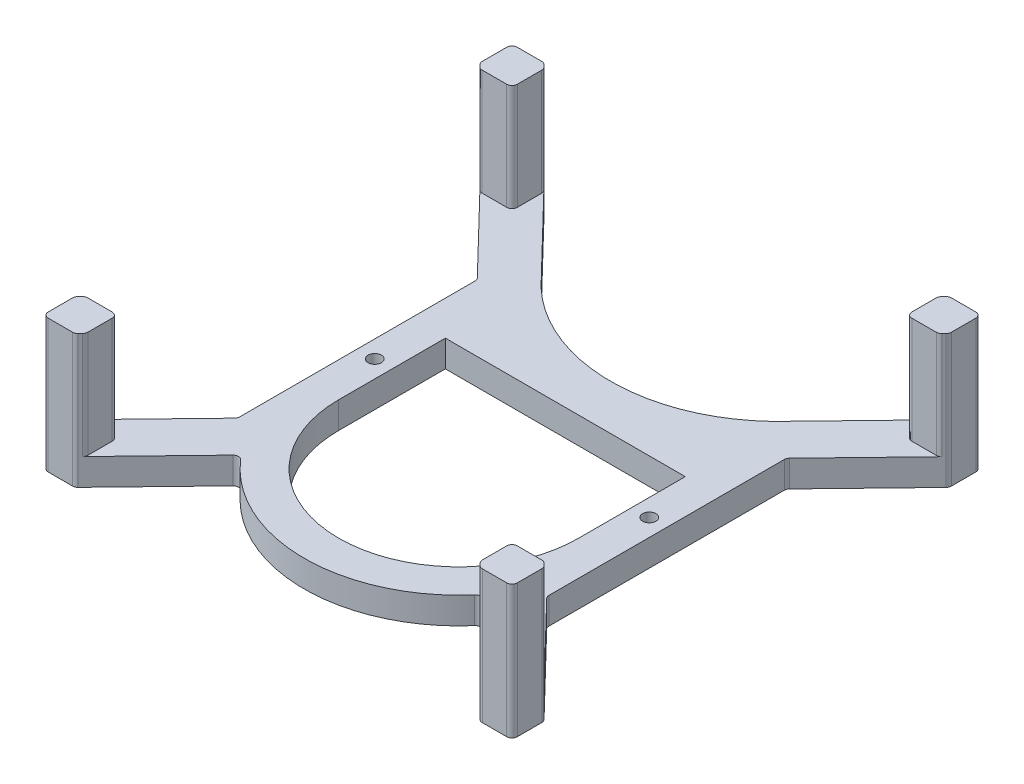
from build123d import *

# Parameters (mm, degrees)
BOSS_EXTRUDE1_DEPTH             = 5
BOSS_EXTRUDE2_DEPTH             = 20
TAP_DRILL_FOR_M3X0_5_TAP1_D     = 2.5
TAP_DRILL_FOR_M3X0_5_TAP1_DEPTH = 6
TAP_DRILL_FOR_M3X0_5_TAP1_TIP   = 0.751075774


with BuildPart() as part:
    # Sketch1 → Boss-Extrude1 (new body)
    with BuildSketch(Plane(origin=(0, 0, 0), x_dir=(1, 0, 0), z_dir=(0, 1, 0))):
        with BuildLine():
            Line((21, 27.921142965), (21, 72.078857035))
            ThreePointArc((21, 72.078857035), (20.927086518, 72.453704455), (20.718978822, 72.773889015))
            Line((20.718978822, 72.773889015), (6.281021178, 87.709296434))
            ThreePointArc((6.281021178, 87.709296434), (6.072913482, 88.029480993), (6, 88.404328413))
            Line((6, 88.404328413), (6, 93))
            ThreePointArc((6, 93), (6.292893219, 93.707106781), (7, 94))
            Line((7, 94), (11.575831706, 94))
            ThreePointArc((11.575831706, 94), (11.966323717, 93.920606316), (12.294810529, 93.69503198))
            Line((12.294810529, 93.69503198), (26.579929079, 78.91772962))
            ThreePointArc((26.579929079, 78.91772962), (50, 68.488702878), (73.420070921, 78.91772962))
            Line((73.420070921, 78.91772962), (87.705189471, 93.69503198))
            ThreePointArc((87.705189471, 93.69503198), (88.033676283, 93.920606316), (88.424168294, 94))
            Line((88.424168294, 94), (93, 94))
            ThreePointArc((93, 94), (93.707106781, 93.707106781), (94, 93))
            Line((94, 93), (94, 88.404328413))
            ThreePointArc((94, 88.404328413), (93.927086518, 88.029480993), (93.718978822, 87.709296434))
            Line((93.718978822, 87.709296434), (79.281021178, 72.773889015))
            ThreePointArc((79.281021178, 72.773889015), (79.072913482, 72.453704455), (79, 72.078857035))
            Line((79, 72.078857035), (79, 27.921142965))
            ThreePointArc((79, 27.921142965), (79.072913482, 27.546295545), (79.281021178, 27.226110985))
            Line((79.281021178, 27.226110985), (93.718978822, 12.290703566))
            ThreePointArc((93.718978822, 12.290703566), (93.927086518, 11.970519007), (94, 11.595671587))
            Line((94, 11.595671587), (94, 7))
            ThreePointArc((94, 7), (93.707106781, 6.292893219), (93, 6))
            Line((93, 6), (88.424168294, 6))
            ThreePointArc((88.424168294, 6), (88.033676283, 6.079393684), (87.705189471, 6.30496802))
            Line((87.705189471, 6.30496802), (73.420070921, 21.08227038))
            ThreePointArc((73.420070921, 21.08227038), (72.67313409, 21.386847499), (71.944389028, 21.040997121))
            ThreePointArc((71.944389028, 21.040997121), (50, 11), (28.055610972, 21.040997121))
            ThreePointArc((28.055610972, 21.040997121), (27.32686591, 21.386847499), (26.579929079, 21.08227038))
            Line((26.579929079, 21.08227038), (12.294810529, 6.30496802))
            ThreePointArc((12.294810529, 6.30496802), (11.966323717, 6.079393684), (11.575831706, 6))
            Line((11.575831706, 6), (7, 6))
            ThreePointArc((7, 6), (6.292893219, 6.292893219), (6, 7))
            Line((6, 7), (6, 11.595671587))
            ThreePointArc((6, 11.595671587), (6.072913482, 11.970519007), (6.281021178, 12.290703566))
            Line((6.281021178, 12.290703566), (20.718978822, 27.226110985))
            ThreePointArc((20.718978822, 27.226110985), (20.927086518, 27.546295545), (21, 27.921142965))
        make_face()
        with BuildLine():
            Line((27.5, 40), (27.5, 60))
            Line((27.5, 60), (72.5, 60))
            Line((72.5, 60), (72.5, 40))
            ThreePointArc((72.5, 40), (50, 17.5), (27.5, 40))
        make_face(mode=Mode.SUBTRACT)
    extrude(amount=BOSS_EXTRUDE1_DEPTH)

    # Sketch2 → Boss-Extrude2 (add)
    with BuildSketch(Plane(origin=(0, 5, 0), x_dir=(1, 0, 0), z_dir=(0, 1, 0))):
        with BuildLine():
            Line((11.575831706, 94), (7, 94))
            ThreePointArc((7, 94), (6.292893219, 93.707106781), (6, 93))
            Line((6, 93), (6, 88.404328413))
            ThreePointArc((6, 88.404328413), (6.072913482, 88.029480993), (6.281021178, 87.709296434))
            Line((6.281021178, 87.709296434), (6.671882728, 87.30496802))
            ThreePointArc((6.671882728, 87.30496802), (7.00036954, 87.079393684), (7.390861551, 87))
            Line((7.390861551, 87), (12, 87))
            ThreePointArc((12, 87), (12.707106781, 87.292893219), (13, 88))
            Line((13, 88), (13, 92.561217283))
            ThreePointArc((13, 92.561217283), (12.927086518, 92.936064704), (12.718978822, 93.256249263))
            Line((12.718978822, 93.256249263), (12.294810529, 93.69503198))
            ThreePointArc((12.294810529, 93.69503198), (11.966323717, 93.920606316), (11.575831706, 94))
        make_face()
        with BuildLine():
            Line((87, 88), (87, 92.561217283))
            ThreePointArc((87, 92.561217283), (87.072913482, 92.936064704), (87.281021178, 93.256249263))
            Line((87.281021178, 93.256249263), (87.705189471, 93.69503198))
            ThreePointArc((87.705189471, 93.69503198), (88.033676283, 93.920606316), (88.424168294, 94))
            Line((88.424168294, 94), (93, 94))
            ThreePointArc((93, 94), (93.707106781, 93.707106781), (94, 93))
            Line((94, 93), (94, 88.404328413))
            ThreePointArc((94, 88.404328413), (93.927086518, 88.029480993), (93.718978822, 87.709296434))
            Line((93.718978822, 87.709296434), (93.328117272, 87.30496802))
            ThreePointArc((93.328117272, 87.30496802), (92.99963046, 87.079393684), (92.609138449, 87))
            Line((92.609138449, 87), (88, 87))
            ThreePointArc((88, 87), (87.292893219, 87.292893219), (87, 88))
        make_face()
        with BuildLine():
            Line((88.424168294, 6), (93, 6))
            ThreePointArc((93, 6), (93.707106781, 6.292893219), (94, 7))
            Line((94, 7), (94, 11.595671587))
            ThreePointArc((94, 11.595671587), (93.927086518, 11.970519007), (93.718978822, 12.290703566))
            Line((93.718978822, 12.290703566), (93.328117272, 12.69503198))
            ThreePointArc((93.328117272, 12.69503198), (92.99963046, 12.920606316), (92.609138449, 13))
            Line((92.609138449, 13), (88, 13))
            ThreePointArc((88, 13), (87.292893219, 12.707106781), (87, 12))
            Line((87, 12), (87, 7.438782717))
            ThreePointArc((87, 7.438782717), (87.072913482, 7.063935296), (87.281021178, 6.743750737))
            Line((87.281021178, 6.743750737), (87.705189471, 6.30496802))
            ThreePointArc((87.705189471, 6.30496802), (88.033676283, 6.079393684), (88.424168294, 6))
        make_face()
        with BuildLine():
            Line((13, 12), (13, 7.438782717))
            ThreePointArc((13, 7.438782717), (12.927086518, 7.063935296), (12.718978822, 6.743750737))
            Line((12.718978822, 6.743750737), (12.294810529, 6.30496802))
            ThreePointArc((12.294810529, 6.30496802), (11.966323717, 6.079393684), (11.575831706, 6))
            Line((11.575831706, 6), (7, 6))
            ThreePointArc((7, 6), (6.292893219, 6.292893219), (6, 7))
            Line((6, 7), (6, 11.595671587))
            ThreePointArc((6, 11.595671587), (6.072913482, 11.970519007), (6.281021178, 12.290703566))
            Line((6.281021178, 12.290703566), (6.671882728, 12.69503198))
            ThreePointArc((6.671882728, 12.69503198), (7.00036954, 12.920606316), (7.390861551, 13))
            Line((7.390861551, 13), (12, 13))
            ThreePointArc((12, 13), (12.707106781, 12.707106781), (13, 12))
        make_face()
    extrude(amount=BOSS_EXTRUDE2_DEPTH)

    # Tap Drill for M3x0.5 Tap1
    with Locations(Plane(origin=(24.25, 5, -50), x_dir=(0, 0, 1), z_dir=(0, 1, 0))):
        with Locations((0, 0), (0, 51.5)):
            Hole(TAP_DRILL_FOR_M3X0_5_TAP1_D / 2, depth=TAP_DRILL_FOR_M3X0_5_TAP1_DEPTH)
            with Locations((0, 0, -(TAP_DRILL_FOR_M3X0_5_TAP1_DEPTH + TAP_DRILL_FOR_M3X0_5_TAP1_TIP / 2))):  # 118° drill point
                Cone(0, TAP_DRILL_FOR_M3X0_5_TAP1_D / 2, TAP_DRILL_FOR_M3X0_5_TAP1_TIP, mode=Mode.SUBTRACT)


solid = part.part
